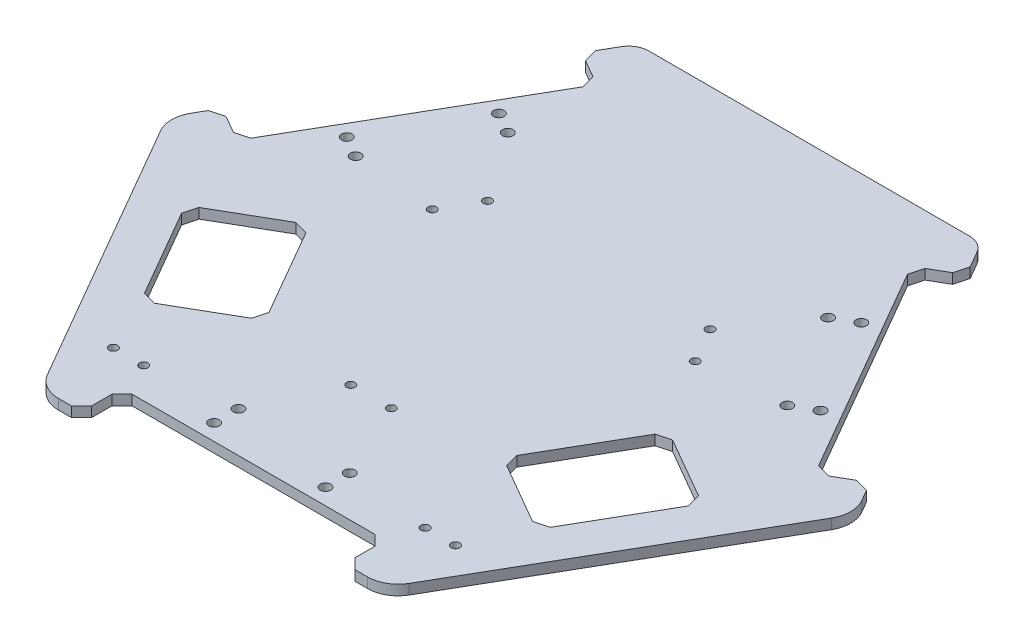
from build123d import *

# Parameters (mm, degrees)
EXTRUDE_1_DEPTH            = 5
SKETCH_16_W                = 130
SKETCH_16_H                = 20
CUT_EXTRUDE_16_DEPTH       = 10
SKETCH_9_R                 = 2.6
CUT_EXTRUDE_8_DEPTH        = 225.944437584
CUT_EXTRUDE_17_REACH       = 226.944
SKETCH_18_R                = 2.1
PATTERN_CIRCULAR_1_COUNT   = 3
CHAMFER_4_SIZE             = 5
SKETCH_5_R                 = 2.1
CUT_EXTRUDE_5_DEPTH        = 225.944437584
CUT_EXTRUDE_7_DEPTH        = 225.944437584
CHAMFER_2_SIZE             = 5
CHAMFER_2_OF_MIRROR_1_SIZE = 5
FILLET_2_R                 = 15
FILLET_3_R                 = 10


with BuildPart() as part:
    # 草圖1 → 填料-伸長1 (new body)
    with BuildSketch(Plane(origin=(0, 0, 0), x_dir=(1, 0, 0), z_dir=(0, 1, 0))):
        Polygon((85, 147.224318643), (-85, 147.224318643), (-170, 0), (-85, -147.224318643), (85, -147.224318643), (170, 0), align=None)
    extrude(amount=EXTRUDE_1_DEPTH)

    # 草圖16 → 除料-伸長16 (cut)
    with BuildSketch(Plane(origin=(0, 5, 0), x_dir=(1, 0, 0), z_dir=(0, 1, 0))):
        with Locations((0, -137.224318643)):
            Rectangle(SKETCH_16_W, SKETCH_16_H)
    cut_extrude_16 = extrude(amount=-CUT_EXTRUDE_16_DEPTH, mode=Mode.SUBTRACT)

    # 草圖9 → 除料-伸長8 (cut, symmetric)
    with BuildSketch(Plane(origin=(0, 5, 0), x_dir=(1, 0, 0), z_dir=(0, 1, 0))):
        with Locations((-27.5, -119.224318643)):
            Circle(SKETCH_9_R)
        with Locations((-27.5, -107.224318643)):
            Circle(SKETCH_9_R)
        with Locations((27.5, -107.224318643)):
            Circle(SKETCH_9_R)
        with Locations((27.5, -119.224318643)):
            Circle(SKETCH_9_R)
    cut_extrude_8 = extrude(amount=CUT_EXTRUDE_8_DEPTH, both=True, mode=Mode.SUBTRACT)

    # 草圖18 → 除料-伸長17 (cut, up to next)
    with BuildSketch(Plane(origin=(0, 5, 0), x_dir=(1, 0, 0), z_dir=(0, 1, 0)), mode=Mode.PRIVATE) as cut_extrude_17_sk1:
        with Locations((-10, -69.224318643)):
            Circle(SKETCH_18_R)
    cut_extrude_17_tool1 = extrude(cut_extrude_17_sk1.sketch, amount=-CUT_EXTRUDE_17_REACH, mode=Mode.PRIVATE) & part.part
    # 草圖18 → 除料-伸長17 (cut, up to next)
    with BuildSketch(Plane(origin=(0, 5, 0), x_dir=(1, 0, 0), z_dir=(0, 1, 0)), mode=Mode.PRIVATE) as cut_extrude_17_sk2:
        with Locations((10, -69.224318643)):
            Circle(SKETCH_18_R)
    cut_extrude_17_tool2 = extrude(cut_extrude_17_sk2.sketch, amount=-CUT_EXTRUDE_17_REACH, mode=Mode.PRIVATE) & part.part
    cut_extrude_17_1 = cut_extrude_17_tool1.solids().sort_by_distance((-10, 5, 69.224319))[0]
    add(cut_extrude_17_1, mode=Mode.SUBTRACT)
    cut_extrude_17_2 = cut_extrude_17_tool2.solids().sort_by_distance((10, 5, 69.224319))[0]
    add(cut_extrude_17_2, mode=Mode.SUBTRACT)
    cut_extrude_17 = cut_extrude_17_1 + cut_extrude_17_2  # 除料-伸長17 as one shape, for the pattern or mirror that repeats it

    # 環狀複製排列1: 除料-伸長16, 除料-伸長8, 除料-伸長17 ×3 about axis
    pattern_circular_1_axis = Axis((0, 5.25, 0), (0, -1, 0))
    add([cut_extrude_16.rotate(pattern_circular_1_axis, i * 360 / PATTERN_CIRCULAR_1_COUNT) for i in range(1, PATTERN_CIRCULAR_1_COUNT)], mode=Mode.SUBTRACT)
    add([cut_extrude_8.rotate(pattern_circular_1_axis, i * 360 / PATTERN_CIRCULAR_1_COUNT) for i in range(1, PATTERN_CIRCULAR_1_COUNT)], mode=Mode.SUBTRACT)
    add([cut_extrude_17.rotate(pattern_circular_1_axis, i * 360 / PATTERN_CIRCULAR_1_COUNT) for i in range(1, PATTERN_CIRCULAR_1_COUNT)], mode=Mode.SUBTRACT)

    # 導角4
    chamfer_4_edges = [part.edges().sort_by_distance(p)[0] for p in [
        (65, 2.5, 127.224318643),
        (65, 2.5, 147.224318643),
        (-65, 2.5, 147.224318643),
        (-65, 2.5, 127.224318643),
        (77.679491924, 2.5, -119.903810568),
        (95, 2.5, -129.903810568),
        (160, 2.5, -17.320508076),
        (142.679491924, 2.5, -7.320508076),
        (-142.679491924, 2.5, -7.320508076),
        (-160, 2.5, -17.320508076),
        (-95, 2.5, -129.903810568),
        (-77.679491924, 2.5, -119.903810568),
    ]]
    chamfer(chamfer_4_edges, length=CHAMFER_4_SIZE)

    # 草圖5 → 除料-伸長5 (cut, through all)
    with BuildSketch(Plane(origin=(0, 5, 0), x_dir=(1, 0, 0), z_dir=(0, 1, 0))):
        with Locations((-84.5, -112)):
            Circle(SKETCH_5_R)
        with Locations((-69.5, -112)):
            Circle(SKETCH_5_R)
        with Locations((84.5, -112)):
            Circle(SKETCH_5_R)
        with Locations((69.5, -112)):
            Circle(SKETCH_5_R)
    extrude(amount=-CUT_EXTRUDE_5_DEPTH, mode=Mode.SUBTRACT)

    # 草圖8 → 除料-伸長7 (cut, through all)
    with BuildSketch(Plane(origin=(0, 5, 0), x_dir=(1, 0, 0), z_dir=(0, 1, 0))):
        Polygon((-127.679491924, -33.301270189), (-97.679491924, -85.262794416), (-58.708348754, -62.762794416), (-88.708348754, -10.801270189), align=None)
    cut_extrude_7 = extrude(amount=-CUT_EXTRUDE_7_DEPTH, mode=Mode.SUBTRACT)

    # 導角2
    chamfer_2_edges = [part.edges().sort_by_distance(p)[0] for p in [
        (-58.708348754, 2.5, 62.762794416),
        (-97.679491924, 2.5, 85.262794416),
        (-127.679491924, 2.5, 33.301270189),
        (-88.708348754, 2.5, 10.801270189),
    ]]
    chamfer(chamfer_2_edges, length=CHAMFER_2_SIZE)

    # 鏡射1: 除料-伸長7 across plane
    add(cut_extrude_7.mirror(Plane(origin=(0, 0, 0), x_dir=(0, 0, 1), z_dir=(1, 0, 0))), mode=Mode.SUBTRACT)

    # 導角2 of 鏡射1
    chamfer_2_of_mirror_1_edges = [part.edges().sort_by_distance(p)[0] for p in [
        (58.708348754, 2.5, 62.762794416),
        (97.679491924, 2.5, 85.262794416),
        (127.679491924, 2.5, 33.301270189),
        (88.708348754, 2.5, 10.801270189),
    ]]
    chamfer(chamfer_2_of_mirror_1_edges, length=CHAMFER_2_OF_MIRROR_1_SIZE)

    # 圓角2
    fillet_2_edges = [part.edges().sort_by_distance(p)[0] for p in [
        (-170, 2.5, 0),
        (-85, 2.5, 147.224318643),
        (85, 2.5, 147.224318643),
        (170, 2.5, 0),
    ]]
    fillet(fillet_2_edges, radius=FILLET_2_R)

    # 圓角3
    fillet_3_edges = [part.edges().sort_by_distance(p)[0] for p in [
        (85, 2.5, -147.224318643),
        (-85, 2.5, -147.224318643),
    ]]
    fillet(fillet_3_edges, radius=FILLET_3_R)


solid = part.part
